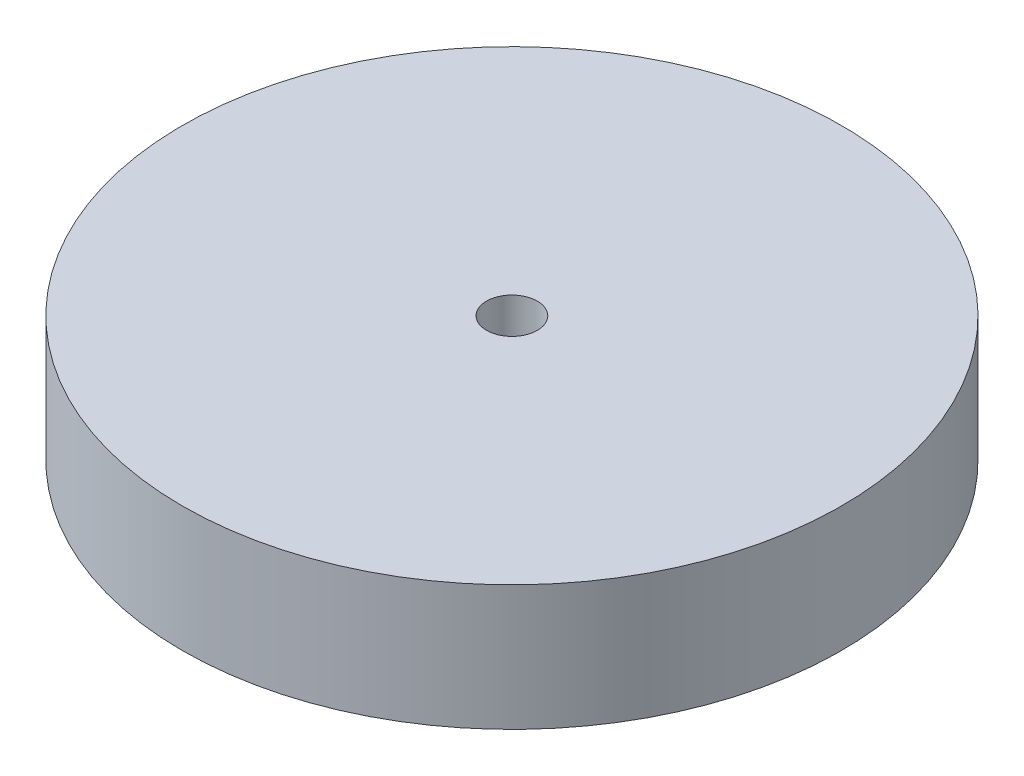
from build123d import *

# Parameters (mm, degrees)
SKETCH1_R           = 50
BOSS_EXTRUDE1_DEPTH = 19
SKETCH2_R           = 3.85
CUT_EXTRUDE2_DEPTH  = 20


with BuildPart() as part:
    # Sketch1 → Boss-Extrude1 (new body)
    with BuildSketch(Plane(origin=(0, 0, 0), x_dir=(1, 0, 0), z_dir=(0, 1, 0))):
        Circle(SKETCH1_R)
    extrude(amount=BOSS_EXTRUDE1_DEPTH)

    # Sketch2 → Cut-Extrude2 (cut, through all)
    with BuildSketch(Plane(origin=(0, 19, 0), x_dir=(1, 0, 0), z_dir=(0, 1, 0))):
        Circle(SKETCH2_R)
    extrude(amount=-CUT_EXTRUDE2_DEPTH, mode=Mode.SUBTRACT)


solid = part.part
